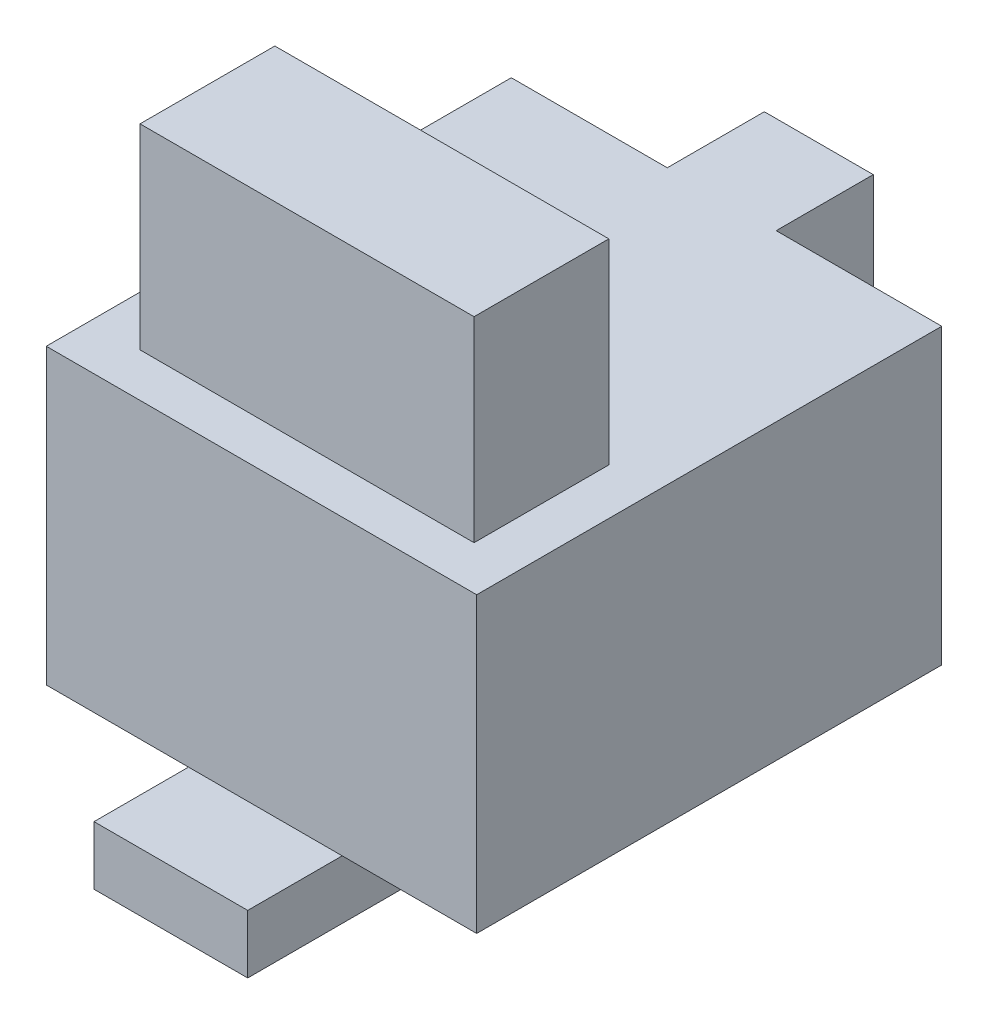
from build123d import *

# Parameters (mm, degrees)
SKETCH1_W           = 39.91
SKETCH1_H           = 43.12
BOSS_EXTRUDE1_DEPTH = 27.2
SKETCH2_W           = 10.1
SKETCH2_H           = 15.13
BOSS_EXTRUDE2_DEPTH = 9
SKETCH5_W           = 14.25
SKETCH5_H           = 14.62
BOSS_EXTRUDE3_DEPTH = 5.43
SKETCH6_W           = 30.97
SKETCH6_H           = 12.5
BOSS_EXTRUDE4_DEPTH = 18.15


with BuildPart() as part:
    # Sketch1 → Boss-Extrude1 (new body)
    with BuildSketch(Plane(origin=(0, 0, 0), x_dir=(1, 0, 0), z_dir=(0, 1, 0))):
        Rectangle(SKETCH1_W, SKETCH1_H)
    extrude(amount=BOSS_EXTRUDE1_DEPTH)

    # Sketch2 → Boss-Extrude2 (add)
    with BuildSketch(Plane(origin=(0, 0, -21.56), x_dir=(-1, 0, 0), z_dir=(0, 0, -1))):
        with Locations((0.445, 19.635)):
            Rectangle(SKETCH2_W, SKETCH2_H)
    extrude(amount=BOSS_EXTRUDE2_DEPTH)

    # Sketch5 → Boss-Extrude3 (add)
    with BuildSketch(Plane.XZ):
        with Locations((0.36, 23.01)):
            Rectangle(SKETCH5_W, SKETCH5_H)
    extrude(amount=BOSS_EXTRUDE3_DEPTH)

    # Sketch6 → Boss-Extrude4 (add)
    with BuildSketch(Plane(origin=(0, 27.2, 0), x_dir=(1, 0, 0), z_dir=(0, 1, 0))):
        with Locations((0.17, -11.254639855)):
            Rectangle(SKETCH6_W, SKETCH6_H)
    extrude(amount=BOSS_EXTRUDE4_DEPTH)


solid = part.part
